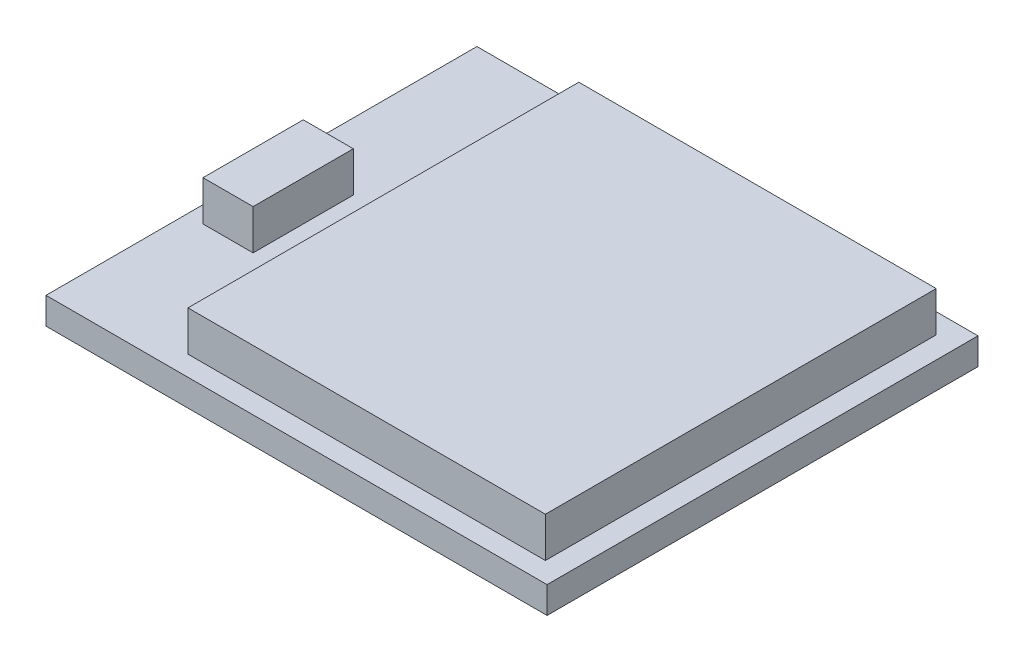
from build123d import *

# Parameters (mm, degrees)
SKETCH1_W           = 15
SKETCH1_H           = 12.9
BOSS_EXTRUDE1_DEPTH = 0.4
SKETCH2_W           = 10.7
SKETCH2_H           = 11.7
BOSS_EXTRUDE2_DEPTH = 1.2
SKETCH3_W           = 1.5
SKETCH3_H           = 3
BOSS_EXTRUDE3_DEPTH = 1.2


with BuildPart() as part:
    # Sketch1 → Boss-Extrude1 (new body, symmetric)
    with BuildSketch(Plane(origin=(0, 0, 0), x_dir=(1, 0, 0), z_dir=(0, 1, 0))):
        Rectangle(SKETCH1_W, SKETCH1_H)
    extrude(amount=BOSS_EXTRUDE1_DEPTH, both=True)

    # Sketch2 → Boss-Extrude2 (add)
    with BuildSketch(Plane(origin=(0, 0.4, 0), x_dir=(1, 0, 0), z_dir=(0, 1, 0))):
        with Locations((1.5, 0)):
            Rectangle(SKETCH2_W, SKETCH2_H)
    extrude(amount=BOSS_EXTRUDE2_DEPTH)

    # Sketch3 → Boss-Extrude3 (add)
    with BuildSketch(Plane(origin=(0, 0.4, 0), x_dir=(1, 0, 0), z_dir=(0, 1, 0))):
        with Locations((-6.25, -0.75)):
            Rectangle(SKETCH3_W, SKETCH3_H)
    extrude(amount=BOSS_EXTRUDE3_DEPTH)


solid = part.part
